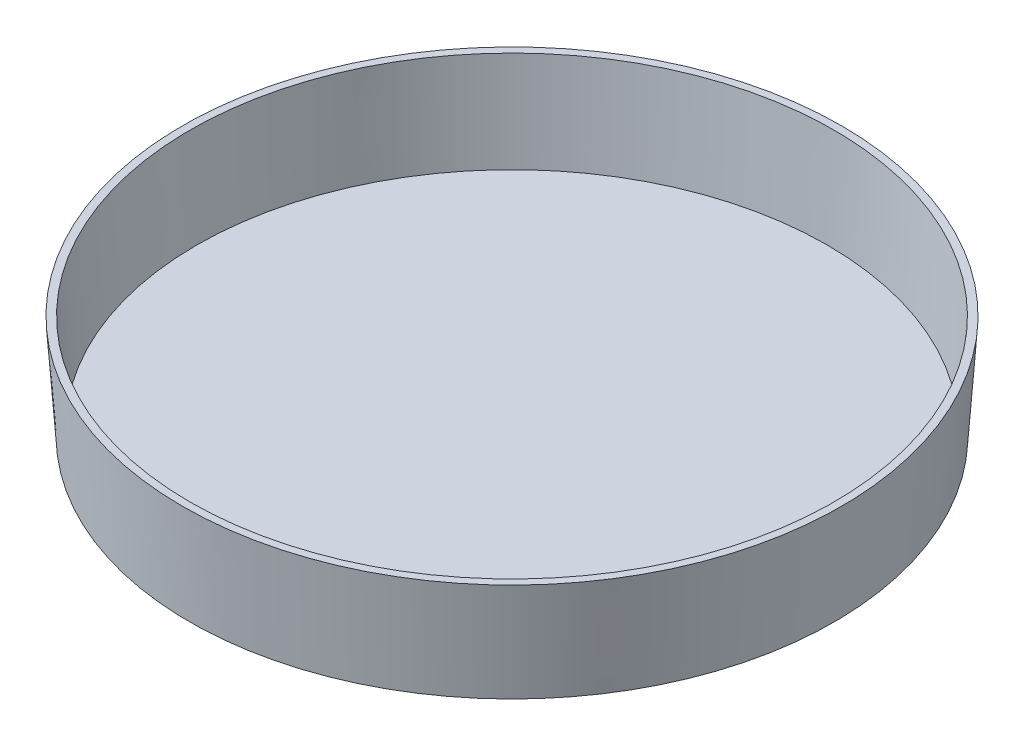
from build123d import *

# Parameters (mm, degrees)
SHELL1_T            = -1.016
SKETCH3_R           = 40.8305
SKETCH3_R_2         = 40.1447
BOSS_EXTRUDE1_DEPTH = 0.762


with BuildPart() as part:
    # Sketch2 → Revolve1 (revolve)
    with BuildSketch(Plane.XY, mode=Mode.PRIVATE) as revolve1_sk:
        Polygon((0, 0), (43.8785, 0), (44.8564, 14.1224), (0, 14.1224), align=None)
    revolve(revolve1_sk.sketch.rotate(Axis((0, 0, 0), (0, 1, 0)), 90), axis=Axis((0, 0, 0), (0, 1, 0)))

    # Shell1
    shell1_openings = [part.faces().sort_by_distance(p)[0] for p in [
        (0, 14.1224, 0),
    ]]
    offset(amount=SHELL1_T, openings=shell1_openings, kind=Kind.INTERSECTION)

    # Sketch3 → Boss-Extrude1 (add)
    with BuildSketch(Plane.XZ):
        with Locations(Location((0, 0, 0), (0, 0, 90))):
            Circle(SKETCH3_R)
        with Locations(Location((0, 0, 0), (0, 0, 90))):
            Circle(SKETCH3_R_2, mode=Mode.SUBTRACT)
    extrude(amount=BOSS_EXTRUDE1_DEPTH)


solid = part.part
